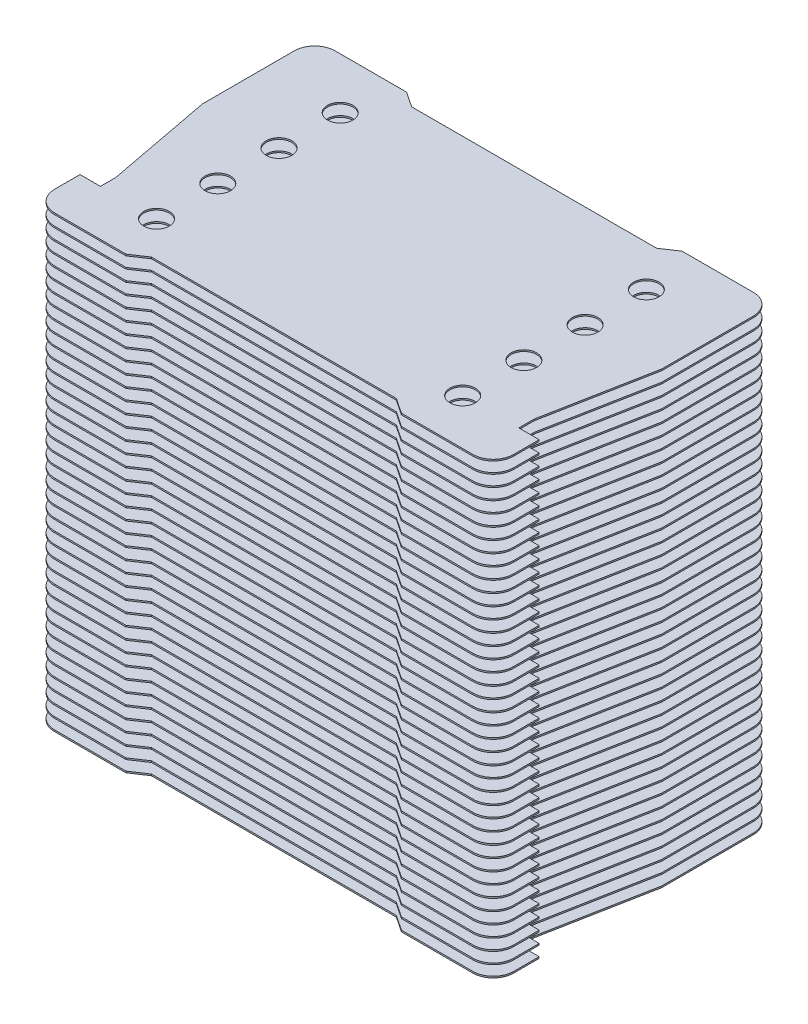
from build123d import *

# Parameters (mm, degrees)
SKETCH1_R           = 2.5
BOSS_EXTRUDE1_DEPTH = 0.3
LPATTERN2_COUNT     = 40
LPATTERN2_PITCH     = 2.25
CUT_EXTRUDE1_DEPTH  = 88.05


with BuildPart() as part:
    # Sketch1 → Boss-Extrude1 (new body)
    with BuildSketch(Plane(origin=(0, 0, 0), x_dir=(1, 0, 0), z_dir=(0, 1, 0))):
        with BuildLine():
            Line((27, 27.5), (41, 27.5))
            ThreePointArc((41, 27.5), (43.828427125, 26.328427125), (45, 23.5))
            Line((45, 23.5), (45, 5.5))
            Line((45, 5.5), (41, -17.578621089))
            Line((41, -17.578621089), (43.739644385, -16.839861537))
            ThreePointArc((43.739644385, -16.839861537), (44.608130079, -17.011536936), (45, -17.80537433))
            Line((45, -17.80537433), (45, -23.5))
            ThreePointArc((45, -23.5), (43.828427125, -26.328427125), (41, -27.5))
            Line((41, -27.5), (27, -27.5))
            Line((27, -27.5), (24, -25.5))
            Line((24, -25.5), (-24, -25.5))
            Line((-24, -25.5), (-27, -27.5))
            Line((-27, -27.5), (-41, -27.5))
            ThreePointArc((-41, -27.5), (-43.828427125, -26.328427125), (-45, -23.5))
            Line((-45, -23.5), (-45, -17.80537433))
            ThreePointArc((-45, -17.80537433), (-44.608130079, -17.011536936), (-43.739644385, -16.839861537))
            Line((-43.739644385, -16.839861537), (-41, -17.578621089))
            Line((-41, -17.578621089), (-45, 5.5))
            Line((-45, 5.5), (-45, 23.5))
            ThreePointArc((-45, 23.5), (-43.828427125, 26.328427125), (-41, 27.5))
            Line((-41, 27.5), (-27, 27.5))
            Line((-27, 27.5), (-24, 25.5))
            Line((-24, 25.5), (24, 25.5))
            Line((24, 25.5), (27, 27.5))
        make_face()
        with Locations((-30, 17.5)):
            Circle(SKETCH1_R, mode=Mode.SUBTRACT)
        with Locations((-30, 5.5)):
            Circle(SKETCH1_R, mode=Mode.SUBTRACT)
        with Locations((-30, -6.5)):
            Circle(SKETCH1_R, mode=Mode.SUBTRACT)
        with Locations((-30, -18.5)):
            Circle(SKETCH1_R, mode=Mode.SUBTRACT)
        with Locations((30, -18.5)):
            Circle(SKETCH1_R, mode=Mode.SUBTRACT)
        with Locations((30, -6.5)):
            Circle(SKETCH1_R, mode=Mode.SUBTRACT)
        with Locations((30, 5.5)):
            Circle(SKETCH1_R, mode=Mode.SUBTRACT)
        with Locations((30, 17.5)):
            Circle(SKETCH1_R, mode=Mode.SUBTRACT)
    extrude(amount=BOSS_EXTRUDE1_DEPTH)


with BuildPart() as lpattern2_1:
    # LPattern2: pattern copy
    add(part.part.moved(Location(Vector(0, 1, 0) * (1 * LPATTERN2_PITCH))))


with BuildPart() as lpattern2_2:
    # LPattern2: pattern copy
    add(part.part.moved(Location(Vector(0, 1, 0) * (2 * LPATTERN2_PITCH))))


with BuildPart() as lpattern2_3:
    # LPattern2: pattern copy
    add(part.part.moved(Location(Vector(0, 1, 0) * (3 * LPATTERN2_PITCH))))


with BuildPart() as lpattern2_4:
    # LPattern2: pattern copy
    add(part.part.moved(Location(Vector(0, 1, 0) * (4 * LPATTERN2_PITCH))))


with BuildPart() as lpattern2_5:
    # LPattern2: pattern copy
    add(part.part.moved(Location(Vector(0, 1, 0) * (5 * LPATTERN2_PITCH))))


with BuildPart() as lpattern2_6:
    # LPattern2: pattern copy
    add(part.part.moved(Location(Vector(0, 1, 0) * (6 * LPATTERN2_PITCH))))


with BuildPart() as lpattern2_7:
    # LPattern2: pattern copy
    add(part.part.moved(Location(Vector(0, 1, 0) * (7 * LPATTERN2_PITCH))))


with BuildPart() as lpattern2_8:
    # LPattern2: pattern copy
    add(part.part.moved(Location(Vector(0, 1, 0) * (8 * LPATTERN2_PITCH))))


with BuildPart() as lpattern2_9:
    # LPattern2: pattern copy
    add(part.part.moved(Location(Vector(0, 1, 0) * (9 * LPATTERN2_PITCH))))


with BuildPart() as lpattern2_10:
    # LPattern2: pattern copy
    add(part.part.moved(Location(Vector(0, 1, 0) * (10 * LPATTERN2_PITCH))))


with BuildPart() as lpattern2_11:
    # LPattern2: pattern copy
    add(part.part.moved(Location(Vector(0, 1, 0) * (11 * LPATTERN2_PITCH))))


with BuildPart() as lpattern2_12:
    # LPattern2: pattern copy
    add(part.part.moved(Location(Vector(0, 1, 0) * (12 * LPATTERN2_PITCH))))


with BuildPart() as lpattern2_13:
    # LPattern2: pattern copy
    add(part.part.moved(Location(Vector(0, 1, 0) * (13 * LPATTERN2_PITCH))))


with BuildPart() as lpattern2_14:
    # LPattern2: pattern copy
    add(part.part.moved(Location(Vector(0, 1, 0) * (14 * LPATTERN2_PITCH))))


with BuildPart() as lpattern2_15:
    # LPattern2: pattern copy
    add(part.part.moved(Location(Vector(0, 1, 0) * (15 * LPATTERN2_PITCH))))


with BuildPart() as lpattern2_16:
    # LPattern2: pattern copy
    add(part.part.moved(Location(Vector(0, 1, 0) * (16 * LPATTERN2_PITCH))))


with BuildPart() as lpattern2_17:
    # LPattern2: pattern copy
    add(part.part.moved(Location(Vector(0, 1, 0) * (17 * LPATTERN2_PITCH))))


with BuildPart() as lpattern2_18:
    # LPattern2: pattern copy
    add(part.part.moved(Location(Vector(0, 1, 0) * (18 * LPATTERN2_PITCH))))


with BuildPart() as lpattern2_19:
    # LPattern2: pattern copy
    add(part.part.moved(Location(Vector(0, 1, 0) * (19 * LPATTERN2_PITCH))))


with BuildPart() as lpattern2_20:
    # LPattern2: pattern copy
    add(part.part.moved(Location(Vector(0, 1, 0) * (20 * LPATTERN2_PITCH))))


with BuildPart() as lpattern2_21:
    # LPattern2: pattern copy
    add(part.part.moved(Location(Vector(0, 1, 0) * (21 * LPATTERN2_PITCH))))


with BuildPart() as lpattern2_22:
    # LPattern2: pattern copy
    add(part.part.moved(Location(Vector(0, 1, 0) * (22 * LPATTERN2_PITCH))))


with BuildPart() as lpattern2_23:
    # LPattern2: pattern copy
    add(part.part.moved(Location(Vector(0, 1, 0) * (23 * LPATTERN2_PITCH))))


with BuildPart() as lpattern2_24:
    # LPattern2: pattern copy
    add(part.part.moved(Location(Vector(0, 1, 0) * (24 * LPATTERN2_PITCH))))


with BuildPart() as lpattern2_25:
    # LPattern2: pattern copy
    add(part.part.moved(Location(Vector(0, 1, 0) * (25 * LPATTERN2_PITCH))))


with BuildPart() as lpattern2_26:
    # LPattern2: pattern copy
    add(part.part.moved(Location(Vector(0, 1, 0) * (26 * LPATTERN2_PITCH))))


with BuildPart() as lpattern2_27:
    # LPattern2: pattern copy
    add(part.part.moved(Location(Vector(0, 1, 0) * (27 * LPATTERN2_PITCH))))


with BuildPart() as lpattern2_28:
    # LPattern2: pattern copy
    add(part.part.moved(Location(Vector(0, 1, 0) * (28 * LPATTERN2_PITCH))))


with BuildPart() as lpattern2_29:
    # LPattern2: pattern copy
    add(part.part.moved(Location(Vector(0, 1, 0) * (29 * LPATTERN2_PITCH))))


with BuildPart() as lpattern2_30:
    # LPattern2: pattern copy
    add(part.part.moved(Location(Vector(0, 1, 0) * (30 * LPATTERN2_PITCH))))


with BuildPart() as lpattern2_31:
    # LPattern2: pattern copy
    add(part.part.moved(Location(Vector(0, 1, 0) * (31 * LPATTERN2_PITCH))))


with BuildPart() as lpattern2_32:
    # LPattern2: pattern copy
    add(part.part.moved(Location(Vector(0, 1, 0) * (32 * LPATTERN2_PITCH))))


with BuildPart() as lpattern2_33:
    # LPattern2: pattern copy
    add(part.part.moved(Location(Vector(0, 1, 0) * (33 * LPATTERN2_PITCH))))


with BuildPart() as lpattern2_34:
    # LPattern2: pattern copy
    add(part.part.moved(Location(Vector(0, 1, 0) * (34 * LPATTERN2_PITCH))))


with BuildPart() as lpattern2_35:
    # LPattern2: pattern copy
    add(part.part.moved(Location(Vector(0, 1, 0) * (35 * LPATTERN2_PITCH))))


with BuildPart() as lpattern2_36:
    # LPattern2: pattern copy
    add(part.part.moved(Location(Vector(0, 1, 0) * (36 * LPATTERN2_PITCH))))


with BuildPart() as lpattern2_37:
    # LPattern2: pattern copy
    add(part.part.moved(Location(Vector(0, 1, 0) * (37 * LPATTERN2_PITCH))))


with BuildPart() as lpattern2_38:
    # LPattern2: pattern copy
    add(part.part.moved(Location(Vector(0, 1, 0) * (38 * LPATTERN2_PITCH))))


with BuildPart() as lpattern2_39:
    # LPattern2: pattern copy
    add(part.part.moved(Location(Vector(0, 1, 0) * (39 * LPATTERN2_PITCH))))


with BuildPart() as cut_extrude1_tool:
    # Sketch3 → Cut-Extrude1 (new body)
    with BuildSketch(Plane.XZ):
        Polygon((41, 18.5), (45, 18.5), (47.215987096, 18.5), (47.215987096, -5.5), (45, -5.5), (41, 15.5), align=None)
        Polygon((-47.215987096, 18.5), (-45, 18.5), (-41, 18.5), (-41, 15.5), (-45, -5.5), (-47.215987096, -5.5), align=None)
    extrude(amount=-CUT_EXTRUDE1_DEPTH)


with BuildPart() as part_1:
    add(part.part)

    # Cut-Extrude1: cut by cut_extrude1_tool
    add(cut_extrude1_tool.part, mode=Mode.SUBTRACT)


with BuildPart() as lpattern2_1_1:
    add(lpattern2_1.part)

    # Cut-Extrude1: cut by cut_extrude1_tool
    add(cut_extrude1_tool.part, mode=Mode.SUBTRACT)


with BuildPart() as lpattern2_2_1:
    add(lpattern2_2.part)

    # Cut-Extrude1: cut by cut_extrude1_tool
    add(cut_extrude1_tool.part, mode=Mode.SUBTRACT)


with BuildPart() as lpattern2_3_1:
    add(lpattern2_3.part)

    # Cut-Extrude1: cut by cut_extrude1_tool
    add(cut_extrude1_tool.part, mode=Mode.SUBTRACT)


with BuildPart() as lpattern2_4_1:
    add(lpattern2_4.part)

    # Cut-Extrude1: cut by cut_extrude1_tool
    add(cut_extrude1_tool.part, mode=Mode.SUBTRACT)


with BuildPart() as lpattern2_5_1:
    add(lpattern2_5.part)

    # Cut-Extrude1: cut by cut_extrude1_tool
    add(cut_extrude1_tool.part, mode=Mode.SUBTRACT)


with BuildPart() as lpattern2_6_1:
    add(lpattern2_6.part)

    # Cut-Extrude1: cut by cut_extrude1_tool
    add(cut_extrude1_tool.part, mode=Mode.SUBTRACT)


with BuildPart() as lpattern2_7_1:
    add(lpattern2_7.part)

    # Cut-Extrude1: cut by cut_extrude1_tool
    add(cut_extrude1_tool.part, mode=Mode.SUBTRACT)


with BuildPart() as lpattern2_8_1:
    add(lpattern2_8.part)

    # Cut-Extrude1: cut by cut_extrude1_tool
    add(cut_extrude1_tool.part, mode=Mode.SUBTRACT)


with BuildPart() as lpattern2_9_1:
    add(lpattern2_9.part)

    # Cut-Extrude1: cut by cut_extrude1_tool
    add(cut_extrude1_tool.part, mode=Mode.SUBTRACT)


with BuildPart() as lpattern2_10_1:
    add(lpattern2_10.part)

    # Cut-Extrude1: cut by cut_extrude1_tool
    add(cut_extrude1_tool.part, mode=Mode.SUBTRACT)


with BuildPart() as lpattern2_11_1:
    add(lpattern2_11.part)

    # Cut-Extrude1: cut by cut_extrude1_tool
    add(cut_extrude1_tool.part, mode=Mode.SUBTRACT)


with BuildPart() as lpattern2_12_1:
    add(lpattern2_12.part)

    # Cut-Extrude1: cut by cut_extrude1_tool
    add(cut_extrude1_tool.part, mode=Mode.SUBTRACT)


with BuildPart() as lpattern2_13_1:
    add(lpattern2_13.part)

    # Cut-Extrude1: cut by cut_extrude1_tool
    add(cut_extrude1_tool.part, mode=Mode.SUBTRACT)


with BuildPart() as lpattern2_14_1:
    add(lpattern2_14.part)

    # Cut-Extrude1: cut by cut_extrude1_tool
    add(cut_extrude1_tool.part, mode=Mode.SUBTRACT)


with BuildPart() as lpattern2_15_1:
    add(lpattern2_15.part)

    # Cut-Extrude1: cut by cut_extrude1_tool
    add(cut_extrude1_tool.part, mode=Mode.SUBTRACT)


with BuildPart() as lpattern2_16_1:
    add(lpattern2_16.part)

    # Cut-Extrude1: cut by cut_extrude1_tool
    add(cut_extrude1_tool.part, mode=Mode.SUBTRACT)


with BuildPart() as lpattern2_17_1:
    add(lpattern2_17.part)

    # Cut-Extrude1: cut by cut_extrude1_tool
    add(cut_extrude1_tool.part, mode=Mode.SUBTRACT)


with BuildPart() as lpattern2_18_1:
    add(lpattern2_18.part)

    # Cut-Extrude1: cut by cut_extrude1_tool
    add(cut_extrude1_tool.part, mode=Mode.SUBTRACT)


with BuildPart() as lpattern2_19_1:
    add(lpattern2_19.part)

    # Cut-Extrude1: cut by cut_extrude1_tool
    add(cut_extrude1_tool.part, mode=Mode.SUBTRACT)


with BuildPart() as lpattern2_20_1:
    add(lpattern2_20.part)

    # Cut-Extrude1: cut by cut_extrude1_tool
    add(cut_extrude1_tool.part, mode=Mode.SUBTRACT)


with BuildPart() as lpattern2_21_1:
    add(lpattern2_21.part)

    # Cut-Extrude1: cut by cut_extrude1_tool
    add(cut_extrude1_tool.part, mode=Mode.SUBTRACT)


with BuildPart() as lpattern2_22_1:
    add(lpattern2_22.part)

    # Cut-Extrude1: cut by cut_extrude1_tool
    add(cut_extrude1_tool.part, mode=Mode.SUBTRACT)


with BuildPart() as lpattern2_23_1:
    add(lpattern2_23.part)

    # Cut-Extrude1: cut by cut_extrude1_tool
    add(cut_extrude1_tool.part, mode=Mode.SUBTRACT)


with BuildPart() as lpattern2_24_1:
    add(lpattern2_24.part)

    # Cut-Extrude1: cut by cut_extrude1_tool
    add(cut_extrude1_tool.part, mode=Mode.SUBTRACT)


with BuildPart() as lpattern2_25_1:
    add(lpattern2_25.part)

    # Cut-Extrude1: cut by cut_extrude1_tool
    add(cut_extrude1_tool.part, mode=Mode.SUBTRACT)


with BuildPart() as lpattern2_26_1:
    add(lpattern2_26.part)

    # Cut-Extrude1: cut by cut_extrude1_tool
    add(cut_extrude1_tool.part, mode=Mode.SUBTRACT)


with BuildPart() as lpattern2_27_1:
    add(lpattern2_27.part)

    # Cut-Extrude1: cut by cut_extrude1_tool
    add(cut_extrude1_tool.part, mode=Mode.SUBTRACT)


with BuildPart() as lpattern2_28_1:
    add(lpattern2_28.part)

    # Cut-Extrude1: cut by cut_extrude1_tool
    add(cut_extrude1_tool.part, mode=Mode.SUBTRACT)


with BuildPart() as lpattern2_29_1:
    add(lpattern2_29.part)

    # Cut-Extrude1: cut by cut_extrude1_tool
    add(cut_extrude1_tool.part, mode=Mode.SUBTRACT)


with BuildPart() as lpattern2_30_1:
    add(lpattern2_30.part)

    # Cut-Extrude1: cut by cut_extrude1_tool
    add(cut_extrude1_tool.part, mode=Mode.SUBTRACT)


with BuildPart() as lpattern2_31_1:
    add(lpattern2_31.part)

    # Cut-Extrude1: cut by cut_extrude1_tool
    add(cut_extrude1_tool.part, mode=Mode.SUBTRACT)


with BuildPart() as lpattern2_32_1:
    add(lpattern2_32.part)

    # Cut-Extrude1: cut by cut_extrude1_tool
    add(cut_extrude1_tool.part, mode=Mode.SUBTRACT)


with BuildPart() as lpattern2_33_1:
    add(lpattern2_33.part)

    # Cut-Extrude1: cut by cut_extrude1_tool
    add(cut_extrude1_tool.part, mode=Mode.SUBTRACT)


with BuildPart() as lpattern2_34_1:
    add(lpattern2_34.part)

    # Cut-Extrude1: cut by cut_extrude1_tool
    add(cut_extrude1_tool.part, mode=Mode.SUBTRACT)


with BuildPart() as lpattern2_35_1:
    add(lpattern2_35.part)

    # Cut-Extrude1: cut by cut_extrude1_tool
    add(cut_extrude1_tool.part, mode=Mode.SUBTRACT)


with BuildPart() as lpattern2_36_1:
    add(lpattern2_36.part)

    # Cut-Extrude1: cut by cut_extrude1_tool
    add(cut_extrude1_tool.part, mode=Mode.SUBTRACT)


with BuildPart() as lpattern2_37_1:
    add(lpattern2_37.part)

    # Cut-Extrude1: cut by cut_extrude1_tool
    add(cut_extrude1_tool.part, mode=Mode.SUBTRACT)


with BuildPart() as lpattern2_38_1:
    add(lpattern2_38.part)

    # Cut-Extrude1: cut by cut_extrude1_tool
    add(cut_extrude1_tool.part, mode=Mode.SUBTRACT)


with BuildPart() as lpattern2_39_1:
    add(lpattern2_39.part)

    # Cut-Extrude1: cut by cut_extrude1_tool
    add(cut_extrude1_tool.part, mode=Mode.SUBTRACT)


solid = Compound([part_1.part, lpattern2_1_1.part, lpattern2_2_1.part, lpattern2_3_1.part, lpattern2_4_1.part, lpattern2_5_1.part, lpattern2_6_1.part, lpattern2_7_1.part, lpattern2_8_1.part, lpattern2_9_1.part, lpattern2_10_1.part, lpattern2_11_1.part, lpattern2_12_1.part, lpattern2_13_1.part, lpattern2_14_1.part, lpattern2_15_1.part, lpattern2_16_1.part, lpattern2_17_1.part, lpattern2_18_1.part, lpattern2_19_1.part, lpattern2_20_1.part, lpattern2_21_1.part, lpattern2_22_1.part, lpattern2_23_1.part, lpattern2_24_1.part, lpattern2_25_1.part, lpattern2_26_1.part, lpattern2_27_1.part, lpattern2_28_1.part, lpattern2_29_1.part, lpattern2_30_1.part, lpattern2_31_1.part, lpattern2_32_1.part, lpattern2_33_1.part, lpattern2_34_1.part, lpattern2_35_1.part, lpattern2_36_1.part, lpattern2_37_1.part, lpattern2_38_1.part, lpattern2_39_1.part])
